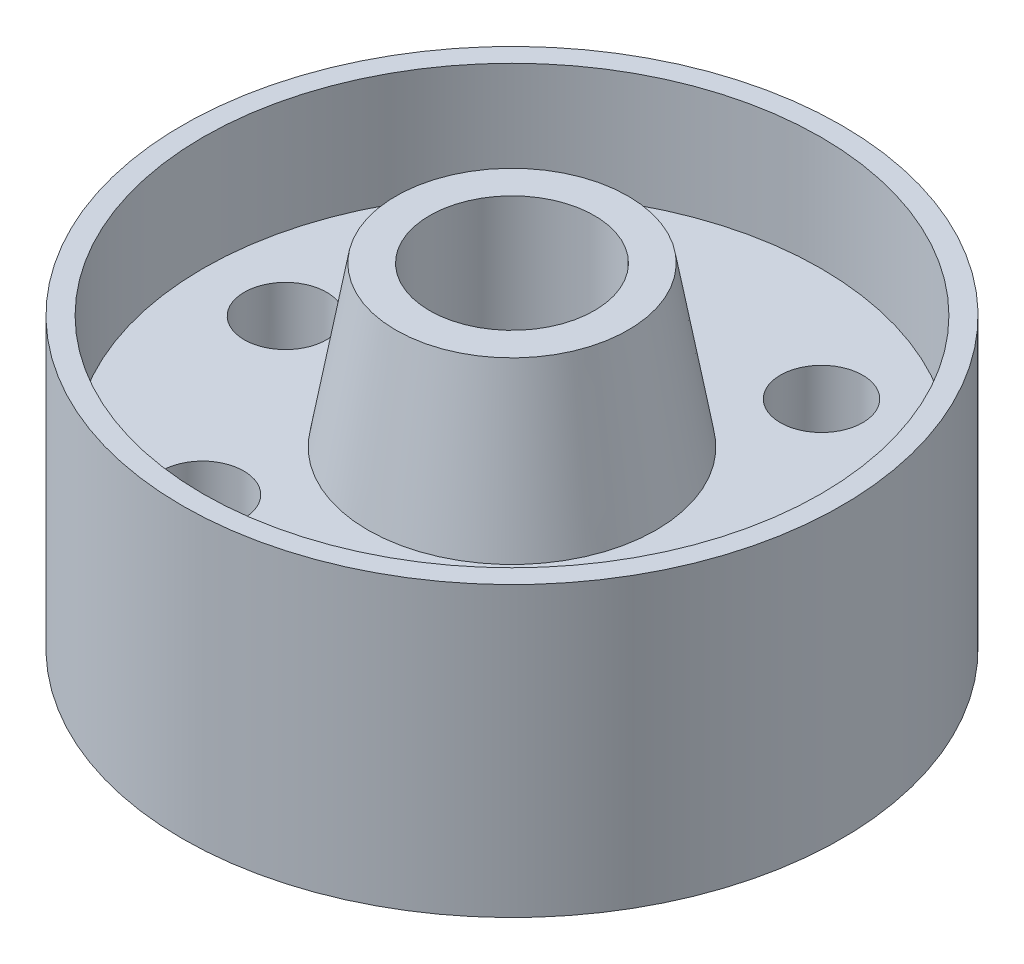
from build123d import *

# Parameters (mm, degrees)
F_1_2_0_5_DIAMETER_HOLE1_D = 12.7


with BuildPart() as part:
    # Sketch1 → Revolve1 (revolve)
    with BuildSketch(Plane.XY):
        Polygon((-12.7, 29.3497), (-17.900810023, 29.3497), (-22.225, 4.826), (-47.625, 4.826), (-47.625, 22.352), (-50.8, 22.352), (-50.8, -22.098), (-47.625, -22.098), (-47.625, -4.826), (-22.225, -4.826), (-17.900810023, -29.3497), (-12.7, -29.3497), align=None)
    revolve(axis=Axis((0, 29.3497, 0), (0, -1, 0)))

    # 1/2 (0.5) Diameter Hole1 (through all)
    with Locations(Plane(origin=(0, 4.826, 0), x_dir=(1, 0, 0), z_dir=(0, 1, 0))):
        with Locations((-17.4625, 30.245937227), (17.4625, 30.245937227), (-34.925, 0), (34.925, 0), (-17.4625, -30.245937227), (17.4625, -30.245937227)):
            Hole(F_1_2_0_5_DIAMETER_HOLE1_D / 2)


solid = part.part
